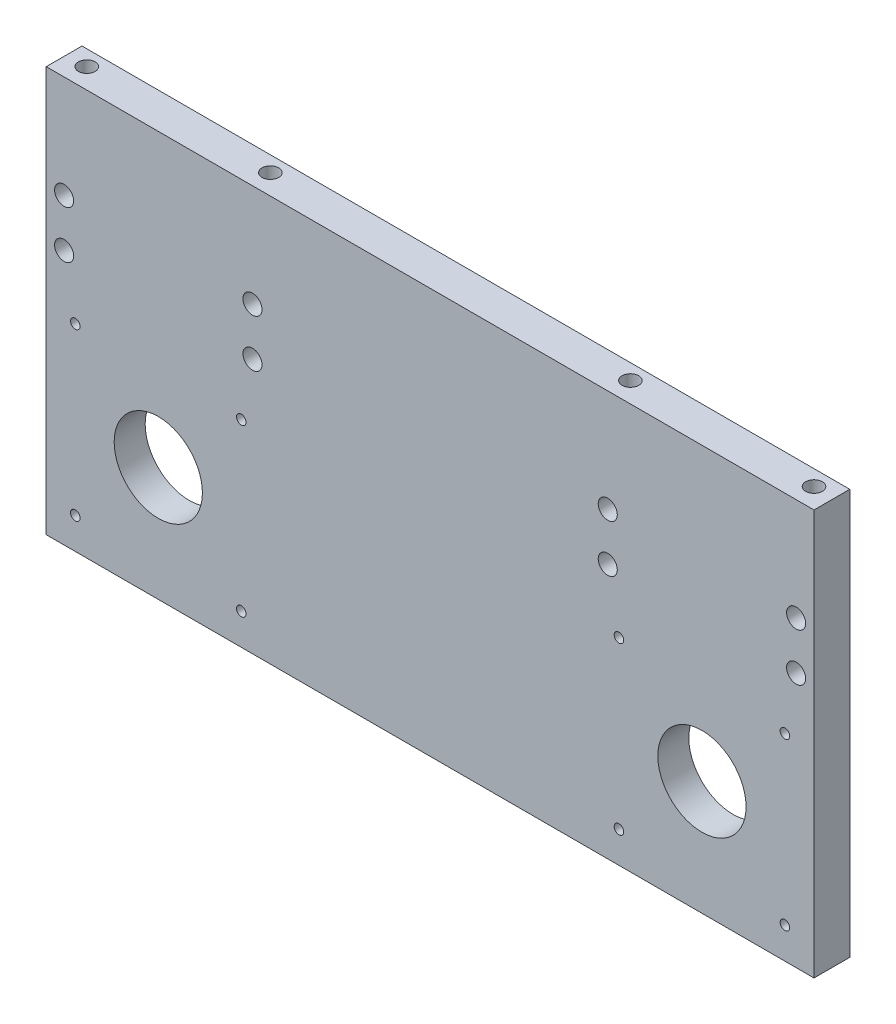
from build123d import *

# Parameters (mm, degrees)
SZKIC1_W                       = 322
SZKIC1_H                       = 170
DODANIE_WYCI_GNI_CIE1_DEPTH    = 15
SZKIC2_R                       = 2
WYTNIJ_WYCI_GNI_CIE2_DEPTH     = 17.75
SZYK_LINIOWY1_COUNT            = 2
SZYK_LINIOWY1_PITCH            = 69.6
SZYK_LINIOWY1_COUNT_DIR2       = 2
SZYK_LINIOWY1_PITCH_DIR2       = 69.6
SZKIC5_R                       = 37.5
WYTNIJ_WYCI_GNI_CIE3_DEPTH     = 2
SZKIC7_R                       = 18.5
WYTNIJ_WYCI_GNI_CIE4_DEPTH     = 17.75
SZKIC10_R                      = 4
WYTNIJ_WYCI_GNI_CIE7_DEPTH     = 183.677311125
SZYK_LINIOWY3_COUNT            = 2
SZYK_LINIOWY3_PITCH            = 79
SZYK_LINIOWY2_COUNT            = 2
SZYK_LINIOWY2_PITCH            = 228
SZYK_LINIOWY2_COPY_1_SKETCH_R  = 2
SZYK_LINIOWY2_COPY_1_DEPTH     = 17.75
SZYK_LINIOWY2_COPY_2_SKETCH_R  = 2
SZYK_LINIOWY2_COPY_2_DEPTH     = 17.75
SZYK_LINIOWY2_COPY_3_SKETCH_R  = 2
SZYK_LINIOWY2_COPY_3_DEPTH     = 17.75
SZYK_LINIOWY2_COPY_4_SKETCH_R  = 4
SZYK_LINIOWY2_COPY_4_DEPTH     = 183.677311125
SZYK_LINIOWY2_COPY_5_SKETCH_R  = 4
SZYK_LINIOWY2_COPY_5_DEPTH     = 183.677311125
OTW_R_GWINTOWANY_M8X1_01_D     = 7
OTW_R_GWINTOWANY_M8X1_01_DEPTH = 21
OTW_R_GWINTOWANY_M8X1_01_TIP   = 2.103012167


with BuildPart() as part:
    # Szkic1 → Dodanie-wyciągnięcie1 (new body)
    with BuildSketch(Plane.XY):
        Rectangle(SZKIC1_W, SZKIC1_H)
    extrude(amount=DODANIE_WYCI_GNI_CIE1_DEPTH)

    # Szkic2 → Wytnij-wyciągnięcie2 (cut)
    with BuildSketch(Plane.XY.offset(15)):
        with Locations((-148.8, -71.87)):
            Circle(SZKIC2_R)
    wytnij_wyci_gni_cie2 = extrude(amount=-WYTNIJ_WYCI_GNI_CIE2_DEPTH, mode=Mode.SUBTRACT)

    # Szyk liniowy1: Wytnij-wyci_gni_cie2 2 × 2
    with Locations(*[(i * SZYK_LINIOWY1_PITCH, j * SZYK_LINIOWY1_PITCH_DIR2, 0) for i in range(SZYK_LINIOWY1_COUNT) for j in range(SZYK_LINIOWY1_COUNT_DIR2) if (i, j) != (0, 0)]):
        add(wytnij_wyci_gni_cie2, mode=Mode.SUBTRACT)

    # Szkic5 → Wytnij-wyciągnięcie3 (cut)
    with BuildSketch(Plane(origin=(0, 0, 0), x_dir=(-1, 0, 0), z_dir=(0, 0, -1))):
        with Locations((114, -37.07)):
            Circle(SZKIC5_R)
    wytnij_wyci_gni_cie3 = extrude(amount=-WYTNIJ_WYCI_GNI_CIE3_DEPTH, mode=Mode.SUBTRACT)

    # Szkic7 → Wytnij-wyciągnięcie4 (cut)
    with BuildSketch(Plane(origin=(0, 0, 2), x_dir=(-1, 0, 0), z_dir=(0, 0, -1))):
        with Locations((114, -37.07)):
            Circle(SZKIC7_R)
    wytnij_wyci_gni_cie4 = extrude(amount=-WYTNIJ_WYCI_GNI_CIE4_DEPTH, mode=Mode.SUBTRACT)

    # Szkic10 → Wytnij-wyciągnięcie7 (cut, through all)
    with BuildSketch(Plane.XY.offset(15)):
        with Locations((-153.5, 42)):
            Circle(SZKIC10_R)
        with Locations((-153.5, 22)):
            Circle(SZKIC10_R)
    wytnij_wyci_gni_cie7 = extrude(amount=-WYTNIJ_WYCI_GNI_CIE7_DEPTH, mode=Mode.SUBTRACT)

    # Szyk liniowy3: Wytnij-wyciągnięcie7 ×2
    with Locations(*[(i * SZYK_LINIOWY3_PITCH, 0, 0) for i in range(1, SZYK_LINIOWY3_COUNT)]):
        add(wytnij_wyci_gni_cie7, mode=Mode.SUBTRACT)

    # Szyk liniowy2: Wytnij-wyciągnięcie2, Wytnij-wyciągnięcie3, Wytnij-wyciągnięcie4 ×2
    with Locations(*[(i * SZYK_LINIOWY2_PITCH, 0, 0) for i in range(1, SZYK_LINIOWY2_COUNT)]):
        add(wytnij_wyci_gni_cie2, mode=Mode.SUBTRACT)
        add(wytnij_wyci_gni_cie3, mode=Mode.SUBTRACT)
        add(wytnij_wyci_gni_cie4, mode=Mode.SUBTRACT)

    # Szyk liniowy2 copy 1 sketch → Szyk liniowy2 copy 1 (cut)
    with BuildSketch(Plane(origin=(228, 69.6, 15), x_dir=(1, 0, 0), z_dir=(0, 0, 1))):
        with Locations((-148.8, -71.87)):
            Circle(SZYK_LINIOWY2_COPY_1_SKETCH_R)
    extrude(amount=-SZYK_LINIOWY2_COPY_1_DEPTH, mode=Mode.SUBTRACT)

    # Szyk liniowy2 copy 2 sketch → Szyk liniowy2 copy 2 (cut)
    with BuildSketch(Plane(origin=(297.6, 0, 15), x_dir=(1, 0, 0), z_dir=(0, 0, 1))):
        with Locations((-148.8, -71.87)):
            Circle(SZYK_LINIOWY2_COPY_2_SKETCH_R)
    extrude(amount=-SZYK_LINIOWY2_COPY_2_DEPTH, mode=Mode.SUBTRACT)

    # Szyk liniowy2 copy 3 sketch → Szyk liniowy2 copy 3 (cut)
    with BuildSketch(Plane(origin=(297.6, 69.6, 15), x_dir=(1, 0, 0), z_dir=(0, 0, 1))):
        with Locations((-148.8, -71.87)):
            Circle(SZYK_LINIOWY2_COPY_3_SKETCH_R)
    extrude(amount=-SZYK_LINIOWY2_COPY_3_DEPTH, mode=Mode.SUBTRACT)

    # Szyk liniowy2 copy 4 sketch → Szyk liniowy2 copy 4 (cut, through all)
    with BuildSketch(Plane(origin=(307, 0, 15), x_dir=(1, 0, 0), z_dir=(0, 0, 1))):
        with Locations((-153.5, 42)):
            Circle(SZYK_LINIOWY2_COPY_4_SKETCH_R)
        with Locations((-153.5, 22)):
            Circle(SZYK_LINIOWY2_COPY_4_SKETCH_R)
    extrude(amount=-SZYK_LINIOWY2_COPY_4_DEPTH, mode=Mode.SUBTRACT)

    # Szyk liniowy2 copy 5 sketch → Szyk liniowy2 copy 5 (cut, through all)
    with BuildSketch(Plane(origin=(228, 0, 15), x_dir=(1, 0, 0), z_dir=(0, 0, 1))):
        with Locations((-153.5, 42)):
            Circle(SZYK_LINIOWY2_COPY_5_SKETCH_R)
        with Locations((-153.5, 22)):
            Circle(SZYK_LINIOWY2_COPY_5_SKETCH_R)
    extrude(amount=-SZYK_LINIOWY2_COPY_5_DEPTH, mode=Mode.SUBTRACT)

    # Otwór gwintowany M8x1.01
    with Locations(Plane(origin=(0, 85, 0), x_dir=(1, 0, 0), z_dir=(0, 1, 0))):
        with Locations((-152.5, -6.5), (-75.5, -6.5), (75.5, -6.5), (152.5, -6.5)):
            Hole(OTW_R_GWINTOWANY_M8X1_01_D / 2, depth=OTW_R_GWINTOWANY_M8X1_01_DEPTH)
            with Locations((0, 0, -(OTW_R_GWINTOWANY_M8X1_01_DEPTH + OTW_R_GWINTOWANY_M8X1_01_TIP / 2))):  # 118° drill point
                Cone(0, OTW_R_GWINTOWANY_M8X1_01_D / 2, OTW_R_GWINTOWANY_M8X1_01_TIP, mode=Mode.SUBTRACT)


solid = part.part
